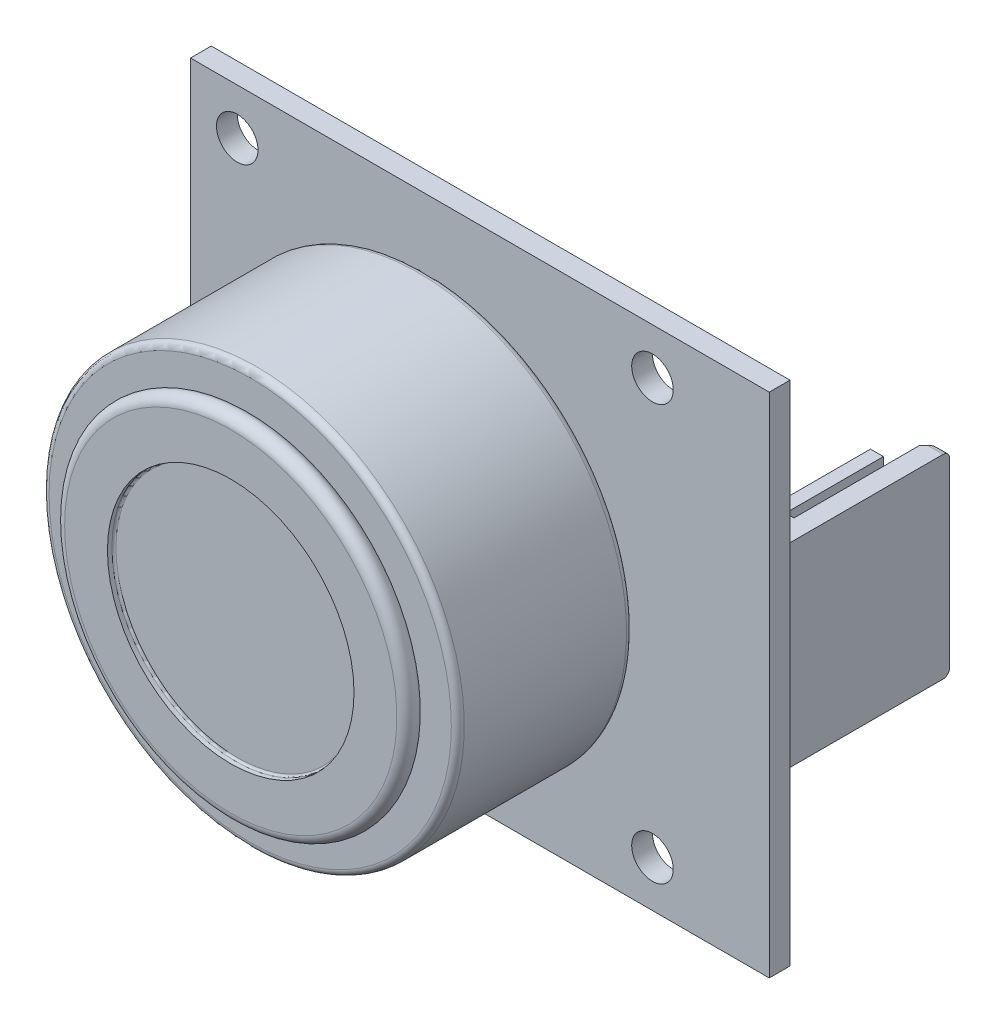
from build123d import *

# Parameters (mm, degrees)
SKETCH1_W           = 44.6
SKETCH1_H           = 39.1
SKETCH1_R           = 1.6
BOSS_EXTRUDE1_DEPTH = 1.6
SKETCH5_W           = 6
SKETCH5_H           = 15
BOSS_EXTRUDE2_DEPTH = 13.5
SKETCH6_W           = 4.5
SKETCH6_H           = 15
SKETCH6_W_2         = 1
SKETCH6_H_2         = 1
CUT_EXTRUDE2_DEPTH  = 10.5
SKETCH7_W           = 1
SKETCH7_H           = 13.7
CUT_EXTRUDE3_DEPTH  = 2
CHAMFER1_SIZE       = 0.3
CHAMFER2_SIZE       = 0.8
FILLET1_R           = 0.5


with BuildPart() as part:
    # Sketch1 → Boss-Extrude1 (new body)
    with BuildSketch(Plane.XY):
        Rectangle(SKETCH1_W, SKETCH1_H)
        with Locations((13.3, 16)):
            Circle(SKETCH1_R, mode=Mode.SUBTRACT)
        with Locations((13.3, -16)):
            Circle(SKETCH1_R, mode=Mode.SUBTRACT)
        with Locations((-18.7, -16)):
            Circle(SKETCH1_R, mode=Mode.SUBTRACT)
        with Locations((-18.7, 16)):
            Circle(SKETCH1_R, mode=Mode.SUBTRACT)
    extrude(amount=BOSS_EXTRUDE1_DEPTH)

    # Sketch3 → Revolve1 (revolve)
    with BuildSketch(Plane(origin=(0, 0, 0), x_dir=(1, 0, 0), z_dir=(0, 1, 0))):
        with BuildLine():
            Line((-2.7, -1.6), (-15.7, -1.6))
            Line((-15.7, -1.6), (-15.7, -2.943633064))
            ThreePointArc((-15.7, -2.943633064), (-15.745798815, -3.054201185), (-15.856366936, -3.1))
            Line((-15.856366936, -3.1), (-18.2, -3.1))
            ThreePointArc((-18.2, -3.1), (-18.553553391, -3.246446609), (-18.7, -3.6))
            Line((-18.7, -3.6), (-18.7, -16.1))
            ThreePointArc((-18.7, -16.1), (-18.553553391, -16.453553391), (-18.2, -16.6))
            Line((-18.2, -16.6), (-15.5, -16.6))
            ThreePointArc((-15.5, -16.6), (-16.25, -17.35), (-15.5, -18.1))
            Line((-15.5, -18.1), (-12.2, -18.1))
            Line((-12.2, -18.1), (-12.2, -17.756366936))
            ThreePointArc((-12.2, -17.756366936), (-12.154201185, -17.645798815), (-12.043633064, -17.6))
            Line((-12.043633064, -17.6), (-2.7, -17.6))
            Line((-2.7, -17.6), (-2.7, -1.6))
        make_face()
    revolve(axis=Axis((-2.7, 0, -11.614281788), (0, 0, 1)))

    # Sketch5 → Boss-Extrude2 (add)
    with BuildSketch(Plane(origin=(0, 0, 0), x_dir=(-1, 0, 0), z_dir=(0, 0, -1))):
        with Locations((-18.1, 0)):
            Rectangle(SKETCH5_W, SKETCH5_H)
    extrude(amount=BOSS_EXTRUDE2_DEPTH)

    # Sketch6 → Cut-Extrude2 (cut)
    with BuildSketch(Plane(origin=(0, 0, -13.5), x_dir=(-1, 0, 0), z_dir=(0, 0, -1))):
        with Locations((-17.35, 0)):
            Rectangle(SKETCH6_W, SKETCH6_H)
        with Locations((-17.8, 6.35)):
            Rectangle(SKETCH6_W_2, SKETCH6_H_2, mode=Mode.SUBTRACT)
        with Locations((-17.8, 3.81)):
            Rectangle(SKETCH6_W_2, SKETCH6_H_2, mode=Mode.SUBTRACT)
        with Locations((-17.8, 1.27)):
            Rectangle(SKETCH6_W_2, SKETCH6_H_2, mode=Mode.SUBTRACT)
        with Locations((-17.8, -1.27)):
            Rectangle(SKETCH6_W_2, SKETCH6_H_2, mode=Mode.SUBTRACT)
        with Locations((-17.8, -3.81)):
            Rectangle(SKETCH6_W_2, SKETCH6_H_2, mode=Mode.SUBTRACT)
        with Locations((-17.8, -6.35)):
            Rectangle(SKETCH6_W_2, SKETCH6_H_2, mode=Mode.SUBTRACT)
    extrude(amount=-CUT_EXTRUDE2_DEPTH, mode=Mode.SUBTRACT)

    # Sketch7 → Cut-Extrude3 (cut)
    with BuildSketch(Plane(origin=(0, 0, -13.5), x_dir=(-1, 0, 0), z_dir=(0, 0, -1))):
        with Locations((-17.8, 0)):
            Rectangle(SKETCH7_W, SKETCH7_H)
    extrude(amount=-CUT_EXTRUDE3_DEPTH, mode=Mode.SUBTRACT)

    # Chamfer1
    chamfer1_edges = [part.edges().sort_by_distance(p)[0] for p in [
        (17.8, -5.85, -11.5),
        (17.8, 5.85, -11.5),
        (17.8, 3.31, -11.5),
        (17.8, 4.31, -11.5),
        (17.8, 0.77, -11.5),
        (17.8, 1.77, -11.5),
        (17.8, -1.77, -11.5),
        (17.8, -0.77, -11.5),
        (17.8, -4.31, -11.5),
        (17.8, -3.31, -11.5),
        (18.3, 6.35, -11.5),
        (18.3, 3.81, -11.5),
        (18.3, 1.27, -11.5),
        (18.3, -1.27, -11.5),
        (18.3, -3.81, -11.5),
        (17.3, 6.35, -11.5),
        (17.3, 3.81, -11.5),
        (17.3, 1.27, -11.5),
        (17.3, -1.27, -11.5),
        (17.3, -3.81, -11.5),
        (18.3, -6.35, -11.5),
        (17.8, 6.85, -11.5),
        (17.3, -6.35, -11.5),
        (17.8, -6.85, -11.5),
    ]]
    chamfer(chamfer1_edges, length=CHAMFER1_SIZE)

    # Chamfer2
    chamfer2_edges = [part.edges().sort_by_distance(p)[0] for p in [
        (19.6, 0, -13.5),
    ]]
    chamfer(chamfer2_edges, length=CHAMFER2_SIZE)

    # Fillet1
    fillet1_edges = [part.edges().sort_by_distance(p)[0] for p in [
        (20.75, 7.5, -13.5),
        (20.75, -7.5, -13.5),
    ]]
    fillet(fillet1_edges, radius=FILLET1_R)


solid = part.part
